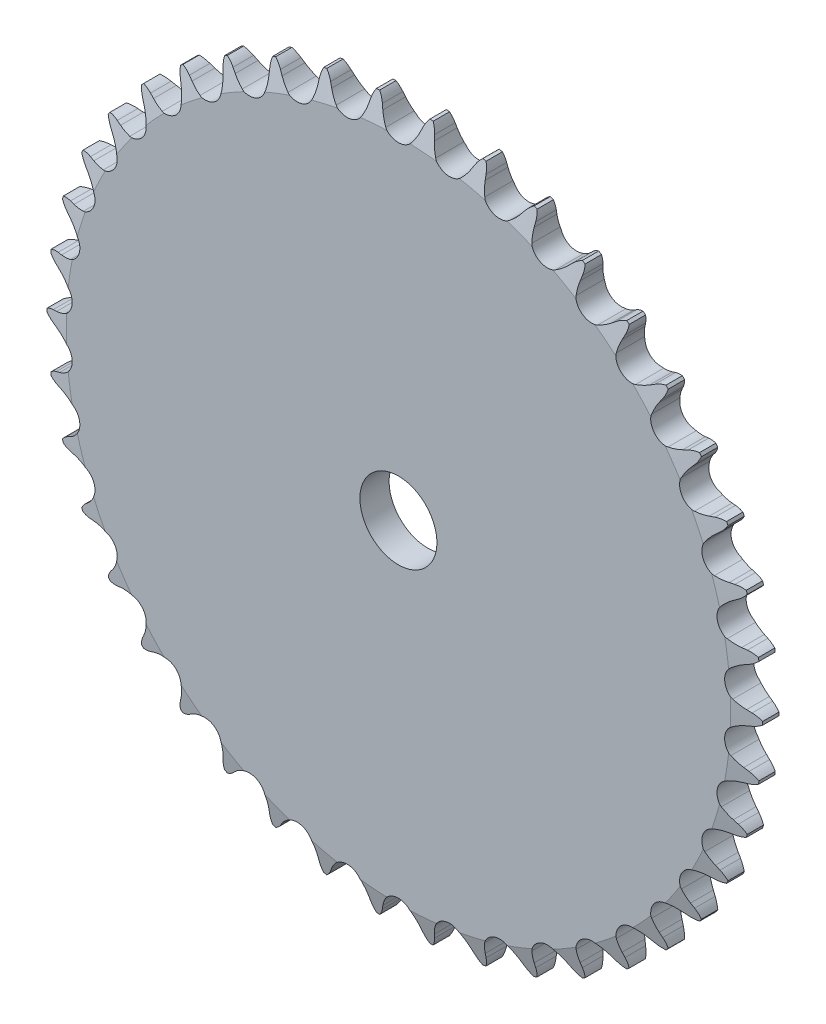
from build123d import *

# Parameters (mm, degrees)
TOOTH_CUT_NUMBER_OF_TEETH_42_DEPTH = 126.27327695
TOOTH_PATTERN_42_42_COUNT          = 42
SKETCH3_W                          = 21.3614
SKETCH3_H                          = 44.45
SKETCH4_R                          = 9.525
CUT_EXTRUDE1_DEPTH                 = 129.289985832
CUT_EXTRUDE5_DEPTH                 = 101.6


with BuildPart() as part:
    # Sprocket-BaseSketch → 40 _08A_ ANSI _ISO_ Chain Number_ 6.691i (revolve)
    with BuildSketch(Plane(origin=(0, 0, 0), x_dir=(0, 0, -1), z_dir=(1, 0, 0))):
        Polygon((3.6068, 0), (3.6068, 82.194861261), (2.0193, 88.544861261), (-2.0193, 88.544861261), (-3.6068, 82.194861261), (-3.6068, 0), align=None)
    revolve(axis=Axis((0, 0, -14.4272), (0, 0, 1)))

    # Tooth-Sketch → Tooth-Cut_ Number of teeth_ 42 (cut, symmetric)
    with BuildSketch(Plane.XY):
        with BuildLine():
            Line((4.648977777, 85.234291997), (5.035171403, 86.309228022))
            ThreePointArc((5.035171403, 86.309228022), (7.378592231, 89.383022071), (11.063696913, 90.549141495))
            ThreePointArc((11.063696913, 90.549141495), (0, 91.222543348), (-11.063696913, 90.549141495))
            ThreePointArc((-11.063696913, 90.549141495), (-7.378592231, 89.383022071), (-5.035171403, 86.309228022))
            Line((-5.035171403, 86.309228022), (-4.648977777, 85.234291997))
            ThreePointArc((-4.648977777, 85.234291997), (-4.038352756, 83.858191345), (-3.234734109, 82.58511908))
            ThreePointArc((-3.234734109, 82.58511908), (0, 80.952149498), (3.234734109, 82.58511908))
            ThreePointArc((3.234734109, 82.58511908), (4.038352756, 83.858191345), (4.648977777, 85.234291997))
        make_face()
    tooth_cut_number_of_teeth_42 = extrude(amount=TOOTH_CUT_NUMBER_OF_TEETH_42_DEPTH, both=True, mode=Mode.SUBTRACT)

    # Tooth Pattern_ 42 _ 42: Tooth-Cut_ Number of teeth_ 42 ×42 about axis
    tooth_pattern_42_42_axis = Axis((0, 0, -88.99), (0, 0, 1))
    for i in range(1, TOOTH_PATTERN_42_42_COUNT):
        add(tooth_cut_number_of_teeth_42.rotate(tooth_pattern_42_42_axis, i * 360 / TOOTH_PATTERN_42_42_COUNT), mode=Mode.SUBTRACT)

    # Sketch3 → Hub-Revolve1 (revolve)
    with BuildSketch(Plane(origin=(0, 0, 0), x_dir=(0, 0, -1), z_dir=(1, 0, 0))):
        with Locations((14.2875, 22.225)):
            Rectangle(SKETCH3_W, SKETCH3_H)
    revolve(axis=Axis((0, 0, 21.3614), (0, 0, -1)))

    # Sketch4 → Cut-Extrude1 (cut, through all)
    with BuildSketch(Plane(origin=(0, 0, -24.9682), x_dir=(-1, 0, 0), z_dir=(0, 0, -1))):
        Circle(SKETCH4_R)
    extrude(amount=-CUT_EXTRUDE1_DEPTH, mode=Mode.SUBTRACT)

    # Sketch11 → Cut-Extrude5 (cut, symmetric)
    with BuildSketch(Plane(origin=(0, 0, 0), x_dir=(1, 0, 0), z_dir=(0, 1, 0))):
        Polygon((101.6, 85.928343329), (-101.6, 85.928343329), (-101.6, 3.6068), (-44.45, 3.6068), (44.45, 3.6068), (101.6, 3.6068), align=None)
    extrude(amount=CUT_EXTRUDE5_DEPTH, both=True, mode=Mode.SUBTRACT)


solid = part.part
